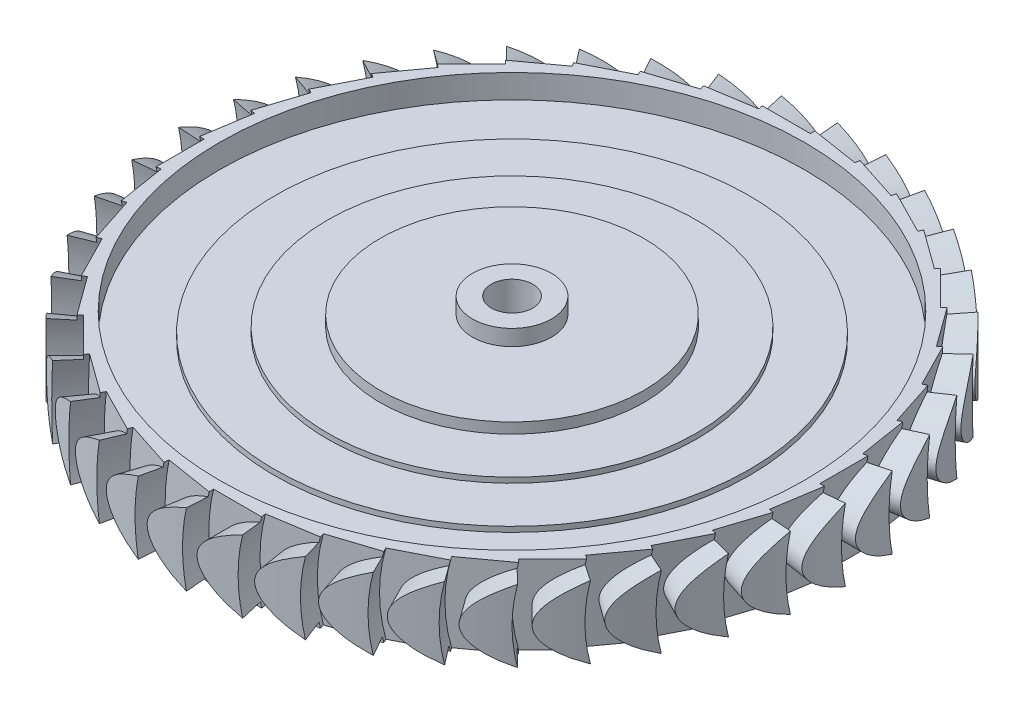
from build123d import *

# Parameters (mm, degrees)
BLADE_CUT_DEPTH   = 6.35
CIRPATTERN1_COUNT = 40


with BuildPart() as part:
    # Sketch3 → Revolve1 (revolve)
    with BuildSketch(Plane.XY):
        Polygon((79.375, -9.525), (79.375, 9.525), (73.025, 9.525), (70.485, 9.525), (70.485, 3.81), (57.15, 3.81), (57.15, 5.08), (44.45, 5.08), (44.45, 6.35), (31.75, 6.35), (31.75, 8.89), (9.525, 8.89), (9.525, 12.7), (5, 12.7), (5, -12.7), (9.525, -12.7), (9.525, -8.89), (31.75, -8.89), (31.75, -6.35), (44.45, -6.35), (44.45, -5.08), (57.15, -5.08), (57.15, -3.81), (70.485, -3.81), (70.485, -9.525), (73.025, -9.525), align=None)
    revolve(axis=Axis((0, -47.50208651, 0), (0, 1, 0)))

    # Sketch2 → Blade Cut (cut)
    with BuildSketch(Plane(origin=(79.375, 0, 0), x_dir=(0, 0, -1), z_dir=(1, 0, 0))):
        with BuildLine():
            Line((1.144218685, -9.525), (15.417809287, -9.525))
            add(Edge.make_bspline(
                [(15.417809287, 9.525), (-9.809527225, 0), (15.417809287, -9.525)],
                knots=[5.845181051, 5.845181051, 5.845181051, 6.721189563, 6.721189563, 6.721189563], degree=2, weights=[1, 0.905599927, 1]))
            Line((15.417809287, 9.525), (1.144218685, 9.525))
            ThreePointArc((1.144218685, 9.525), (0, 0), (1.144218685, -9.525))
        make_face()
    blade_cut = extrude(amount=-BLADE_CUT_DEPTH, mode=Mode.SUBTRACT)

    # CirPattern1: Blade Cut ×40 about axis
    cirpattern1_axis = Axis((0, 20.478259177, 0), (0, -1, 0))
    for i in range(1, CIRPATTERN1_COUNT):
        add(blade_cut.rotate(cirpattern1_axis, i * 360 / CIRPATTERN1_COUNT), mode=Mode.SUBTRACT)


solid = part.part
